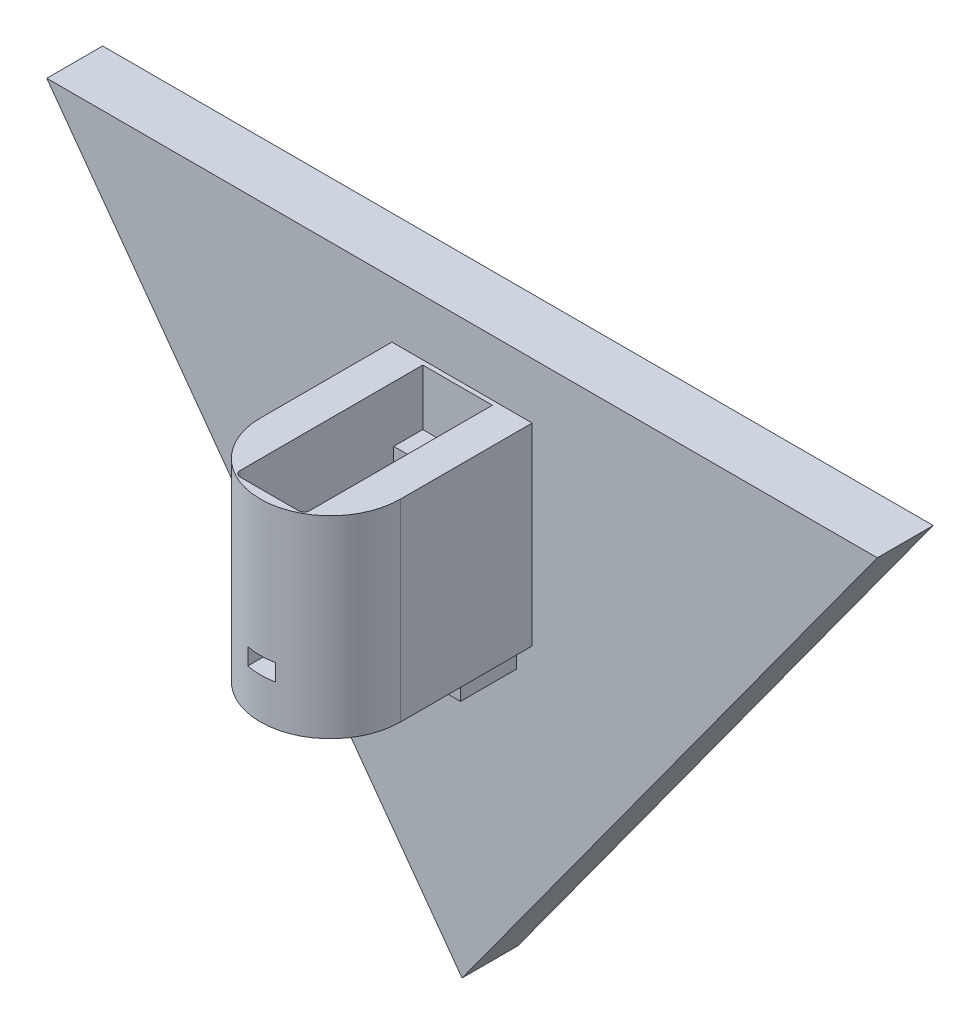
from build123d import *

# Parameters (mm, degrees)
SKETCH4_W                = 12.46
SKETCH4_H                = 17.25
BOSS_EXTRUDE3_DEPTH      = 6
SKETCH8_R                = 12.546781182
SKETCH8_R_2              = 11.15
BOSS_EXTRUDE6_DEPTH      = 7.3
BOSS_EXTRUDE6_DEPTH_BACK = 17.25
BOSS_EXTRUDE4_DEPTH      = 17.25
SKETCH6_R                = 0.5
CUT_EXTRUDE1_DEPTH       = 20
CHAMFER1_SIZE            = 0.5
CHAMFER1_SIZE2           = 0.866025404
SKETCH10_W               = 12.46
SKETCH10_H               = 23.7
CUT_EXTRUDE3_DEPTH       = 17.25
CUT_EXTRUDE4_REACH       = 38.097
SKETCH11_W               = 5
SKETCH11_H               = 3
BOSS_EXTRUDE7_DEPTH      = 7.3
BOSS_EXTRUDE9_DEPTH      = 10
SKETCH16_R               = 11.15
SKETCH16_R_2             = 7.15
BOSS_EXTRUDE10_DEPTH     = 7.3
SKETCH17_R               = 10.15
SKETCH17_R_2             = 7.15
CUT_EXTRUDE5_DEPTH       = 1.3
SKETCH18_W               = 3
SKETCH18_H               = 10
BOSS_EXTRUDE11_DEPTH     = 5
OFFSET_R_DEPTH           = 10


with BuildPart() as part:
    # Sketch4 → Boss-Extrude3 (new body)
    with BuildSketch(Plane.XY):
        with Locations((0, -1.35)):
            Rectangle(SKETCH4_W, SKETCH4_H)
    extrude(amount=BOSS_EXTRUDE3_DEPTH)



with BuildPart() as body_2:
    # Sketch8 → Boss-Extrude6 (new body, two sides)
    with BuildSketch(Plane(origin=(0, -9.975, 0), x_dir=(-1, 0, 0), z_dir=(0, -1, 0))) as boss_extrude6_sk:
        with Locations((0, -23.55)):
            Circle(SKETCH8_R)
        with Locations((0, -23.55)):
            Circle(SKETCH8_R_2, mode=Mode.SUBTRACT)
    extrude(amount=BOSS_EXTRUDE6_DEPTH)
    extrude(boss_extrude6_sk.sketch, amount=-BOSS_EXTRUDE6_DEPTH_BACK)


with BuildPart() as part_1:
    add(part.part)

    add(body_2.part)  # Boss-Extrude4 merges body 2
    # Sketch5 → Boss-Extrude4 (add)
    with BuildSketch(Plane(origin=(0, 7.275, 0), x_dir=(1, 0, 0), z_dir=(0, 1, 0))):
        with BuildLine():
            Line((12.546781182, -23.55), (12.546781182, 0))
            Line((12.546781182, 0), (6.23, 0))
            Line((6.23, 0), (6.23, -29.7))
            Line((6.23, -29.7), (-6.23, -29.7))
            Line((-6.23, -29.7), (-6.23, 0))
            Line((-6.23, 0), (-12.546781182, 0))
            Line((-12.546781182, 0), (-12.546781182, -23.55))
            ThreePointArc((-12.546781182, -23.55), (0, -36.096781182), (12.546781182, -23.55))
        make_face()
    extrude(amount=-BOSS_EXTRUDE4_DEPTH)

    # Sketch6 → Cut-Extrude1 (cut)
    with BuildSketch(Plane(origin=(0, 7.275, 0), x_dir=(1, 0, 0), z_dir=(0, 1, 0))):
        with Locations((0, -3.6)):
            Circle(SKETCH6_R)
        with Locations((0, -32.1)):
            Circle(SKETCH6_R)
    extrude(amount=-CUT_EXTRUDE1_DEPTH, mode=Mode.SUBTRACT)

    # Chamfer1
    chamfer1_edges = [part_1.edges().sort_by_distance(p)[0] for p in [
        (-0.5, 7.275, 3.6),
        (-0.5, 7.275, 32.1),
    ]]
    chamfer1_side = [part_1.faces().sort_by_distance(p)[0] for p in [
        (0, 7.275, 35.657160381),
    ]]
    chamfer(chamfer1_edges, length=CHAMFER1_SIZE, length2=CHAMFER1_SIZE2, reference=chamfer1_side[0])

    # Sketch10 → Cut-Extrude3 (cut)
    with BuildSketch(Plane(origin=(0, 7.275, 0), x_dir=(1, 0, 0), z_dir=(0, 1, 0))):
        with Locations((0, -17.85)):
            Rectangle(SKETCH10_W, SKETCH10_H)
    extrude(amount=-CUT_EXTRUDE3_DEPTH, mode=Mode.SUBTRACT)

    # Sketch11 → Cut-Extrude4 (cut, up to next)
    with BuildSketch(Plane.XY.offset(36.096781182), mode=Mode.PRIVATE) as cut_extrude4_sk1:
        with Locations((0, -8.475)):
            Rectangle(SKETCH11_W, SKETCH11_H)
    cut_extrude4_tool1 = extrude(cut_extrude4_sk1.sketch, amount=-CUT_EXTRUDE4_REACH, mode=Mode.PRIVATE) & part_1.part
    add(cut_extrude4_tool1.solids().sort_by_distance((0, -8.475, 36.096781))[0], mode=Mode.SUBTRACT)

    # Sketch13 → Boss-Extrude7 (add)
    with BuildSketch(Plane.XZ.offset(17.275)):
        with BuildLine():
            Line((-12.546781182, 23.55), (-12.546781182, 0))
            Line((-12.546781182, 0), (12.546781182, 0))
            Line((12.546781182, 0), (12.546781182, 23.55))
            ThreePointArc((12.546781182, 23.55), (0, 11.003218818), (-12.546781182, 23.55))
        make_face()
    extrude(amount=-BOSS_EXTRUDE7_DEPTH)

    # Sketch15 → Boss-Extrude9 (add)
    with BuildSketch(Plane(origin=(0, 7.275, 0), x_dir=(1, 0, 0), z_dir=(0, 1, 0))):
        with BuildLine():
            Line((-12.546781182, 0), (12.546781182, 0))
            Line((12.546781182, 0), (12.546781182, -23.55))
            ThreePointArc((12.546781182, -23.55), (0, -36.096781182), (-12.546781182, -23.55))
            Line((-12.546781182, -23.55), (-12.546781182, 0))
        make_face()
        with BuildLine():
            Line((-6.23, -0.8), (6.23, -0.8))
            Line((6.23, -0.8), (6.23, -33.5))
            ThreePointArc((6.23, -33.5), (5.937106781, -34.207106781), (5.23, -34.5))
            Line((5.23, -34.5), (-5.23, -34.5))
            ThreePointArc((-5.23, -34.5), (-5.937106781, -34.207106781), (-6.23, -33.5))
            Line((-6.23, -33.5), (-6.23, -0.8))
        make_face(mode=Mode.SUBTRACT)
    extrude(amount=BOSS_EXTRUDE9_DEPTH)

    # Sketch16 → Boss-Extrude10 (add)
    with BuildSketch(Plane.XZ.offset(17.275)):
        with Locations((0, 23.55)):
            Circle(SKETCH16_R)
        with Locations((0, 23.55)):
            Circle(SKETCH16_R_2, mode=Mode.SUBTRACT)
    extrude(amount=-BOSS_EXTRUDE10_DEPTH)

    # Sketch17 → Cut-Extrude5 (cut)
    with BuildSketch(Plane.XZ.offset(17.275)):
        with Locations((0, 23.55)):
            Circle(SKETCH17_R)
        with Locations((0, 23.55)):
            Circle(SKETCH17_R_2, mode=Mode.SUBTRACT)
    extrude(amount=-CUT_EXTRUDE5_DEPTH, mode=Mode.SUBTRACT)

    # Sketch18 → Boss-Extrude11 (add)
    with BuildSketch(Plane.XZ.offset(17.275)):
        with Locations((8.23, 5)):
            Rectangle(SKETCH18_W, SKETCH18_H)
        with Locations((3.714, 5)):
            Rectangle(SKETCH18_W, SKETCH18_H)
    extrude(amount=BOSS_EXTRUDE11_DEPTH)

    # Sketch1 → Offset R (add)
    with BuildSketch(Plane.XY):
        Polygon((0, -75), (74.307137052, 27.275), (-74.307137052, 27.275), align=None)
    extrude(amount=-OFFSET_R_DEPTH)


solid = part_1.part
